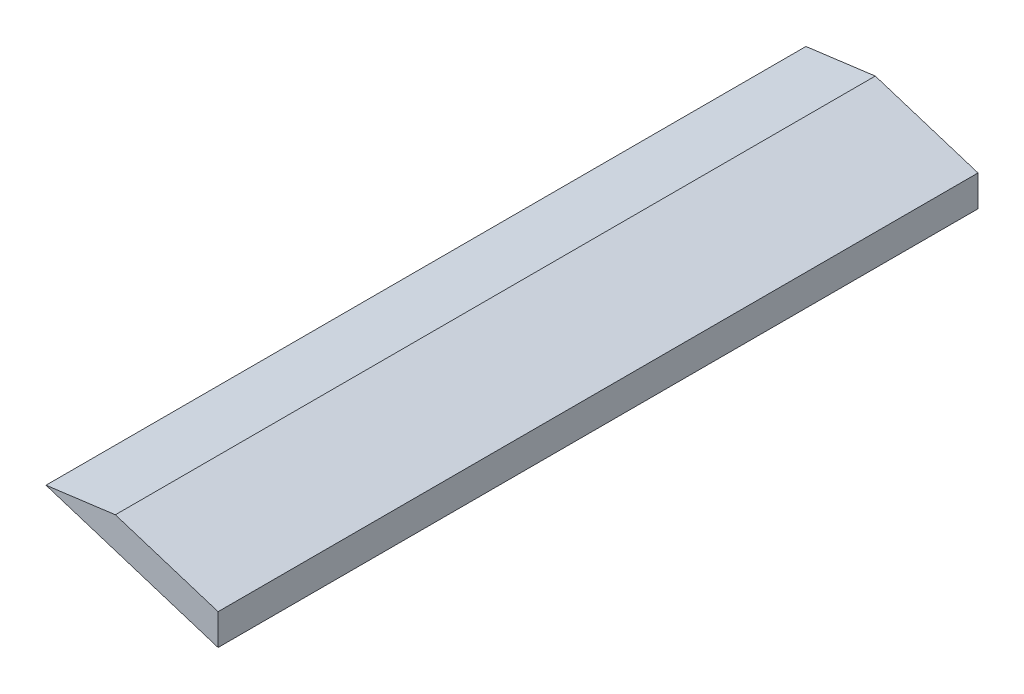
from build123d import *

# Parameters (mm, degrees)
BOSS_EXTRUDE1_DEPTH = 77


with BuildPart() as part:
    # Sketch2 → Boss-Extrude1 (new body)
    with BuildSketch(Plane.XY):
        Polygon((259.099999165, -276.931424676), (259.099998606, -280.078452188), (241.66219208, -274.552555626), (248.69119692, -273.632961394), align=None)
    extrude(amount=BOSS_EXTRUDE1_DEPTH)


solid = part.part
